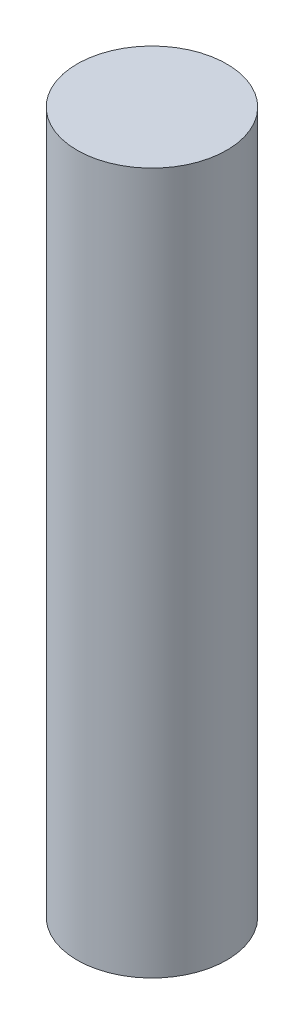
from build123d import *

# Parameters (mm, degrees)
SKETCH_1_R      = 1.6
EXTRUDE_1_DEPTH = 15


with BuildPart() as part:
    # 草圖1 → 填料-伸長1 (new body)
    with BuildSketch(Plane(origin=(0, 0, 0), x_dir=(1, 0, 0), z_dir=(0, 1, 0))):
        Circle(SKETCH_1_R)
    extrude(amount=EXTRUDE_1_DEPTH)


solid = part.part
